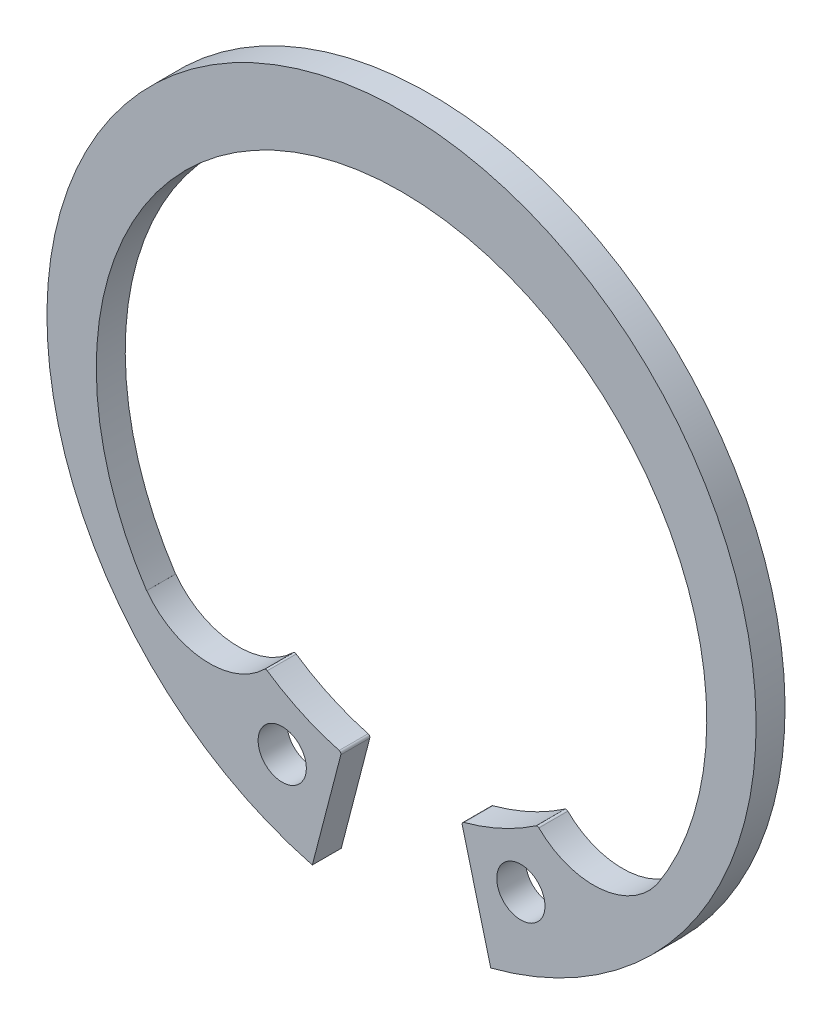
from build123d import *

# Parameters (mm, degrees)
BODYSKE_R    = 1
BODY_DEPTH   = 1.2
MODLUGSKE_R  = 1
MODLUG_DEPTH = 1.2


with BuildPart() as part:
    # BodySke → Body (new body)
    with BuildSketch(Plane.XY):
        with BuildLine():
            Line((3.698325427, -14.227170802), (2.961893262, -11.394173437))
            ThreePointArc((2.961893262, -11.394173437), (3.929191569, -9.098338228), (6.398111495, -9.431444396))
            ThreePointArc((6.398111495, -9.431444396), (7.897695705, -10.033919527), (9.36780531, -9.362721467))
            ThreePointArc((9.36780531, -9.362721467), (0, 11.8), (-9.36780531, -9.362721467))
            ThreePointArc((-9.36780531, -9.362721467), (-7.897695705, -10.033919527), (-6.398111495, -9.431444396))
            ThreePointArc((-6.398111495, -9.431444396), (-3.929191569, -9.098338228), (-2.961893262, -11.394173437))
            Line((-2.961893262, -11.394173437), (-3.698325427, -14.227170802))
            ThreePointArc((-3.698325427, -14.227170802), (0, 14.7), (3.698325427, -14.227170802))
        make_face()
        with Locations((4.945954497, -10.878420571)):
            Circle(BODYSKE_R, mode=Mode.SUBTRACT)
        with Locations((-4.945954497, -10.878420571)):
            Circle(BODYSKE_R, mode=Mode.SUBTRACT)
    extrude(amount=-BODY_DEPTH)

    # ModLugSke → ModLug (add, through all)
    with BuildSketch(Plane.XY):
        with BuildLine():
            Line((3.698325427, -14.227170802), (2.515741841, -9.677863555))
            ThreePointArc((2.515741841, -9.677863555), (2.526047037, -9.602490267), (2.586400063, -9.55617783))
            ThreePointArc((2.586400063, -9.55617783), (4.133747796, -8.995672802), (5.566861748, -8.186577446))
            ThreePointArc((5.566861748, -8.186577446), (5.632003549, -8.169667957), (5.693109271, -8.197872134))
            ThreePointArc((5.693109271, -8.197872134), (8.216340211, -9.113789007), (10.56344638, -7.811218195))
            Line((10.56344638, -7.811218195), (11.81954198, -8.740047333))
            ThreePointArc((11.81954198, -8.740047333), (8.229713434, -12.180386562), (3.698325427, -14.227170802))
        make_face()
        with Locations((4.945954497, -10.878420571)):
            Circle(MODLUGSKE_R, mode=Mode.SUBTRACT)
        with BuildLine():
            Line((-3.698325427, -14.227170802), (-2.515741841, -9.677863555))
            ThreePointArc((-2.515741841, -9.677863555), (-2.526047037, -9.602490267), (-2.586400063, -9.55617783))
            ThreePointArc((-2.586400063, -9.55617783), (-4.133747796, -8.995672802), (-5.566861748, -8.186577446))
            ThreePointArc((-5.566861748, -8.186577446), (-5.632003549, -8.169667957), (-5.693109271, -8.197872134))
            ThreePointArc((-5.693109271, -8.197872134), (-8.216340211, -9.113789007), (-10.56344638, -7.811218195))
            Line((-10.56344638, -7.811218195), (-11.81954198, -8.740047333))
            ThreePointArc((-11.81954198, -8.740047333), (-8.229713434, -12.180386562), (-3.698325427, -14.227170802))
        make_face()
        with Locations((-4.945954497, -10.878420571)):
            Circle(MODLUGSKE_R, mode=Mode.SUBTRACT)
    extrude(amount=-MODLUG_DEPTH)


solid = part.part
